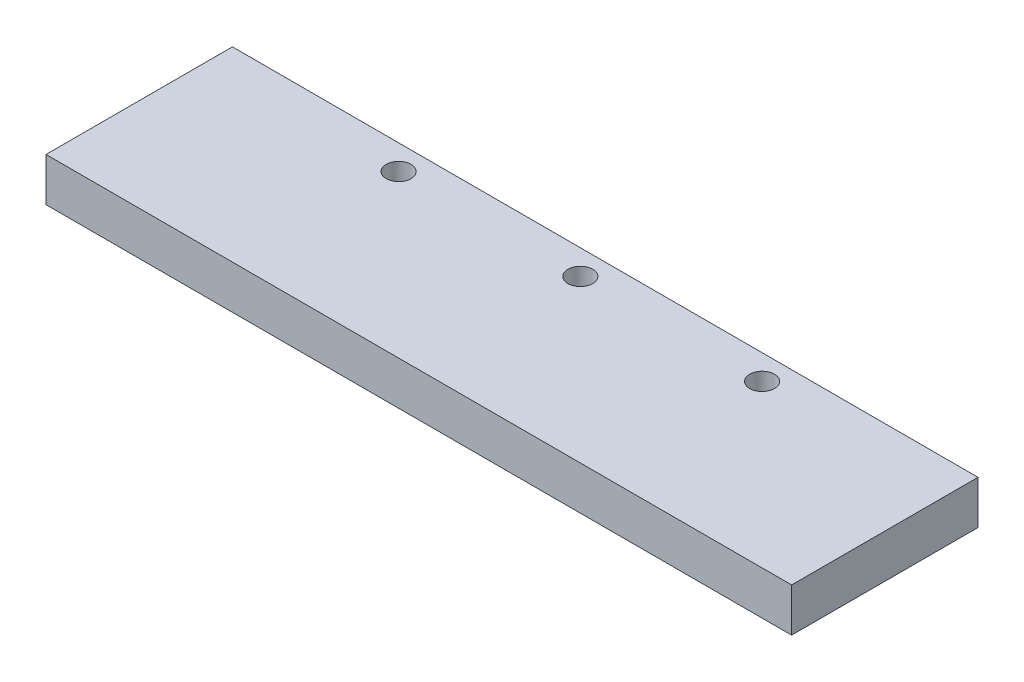
from build123d import *

# Parameters (mm, degrees)
SKETCH1_W           = 120
SKETCH1_H           = 30
BOSS_EXTRUDE1_DEPTH = 7
SKETCH2_R           = 2
CUT_EXTRUDE1_DEPTH  = 10


with BuildPart() as part:
    # Sketch1 → Boss-Extrude1 (new body)
    with BuildSketch(Plane(origin=(0, 0, 0), x_dir=(1, 0, 0), z_dir=(0, 1, 0))):
        with Locations((-42.510460251, 50.167364017)):
            Rectangle(SKETCH1_W, SKETCH1_H)
    extrude(amount=BOSS_EXTRUDE1_DEPTH)

    # Sketch2 → Cut-Extrude1 (cut)
    with BuildSketch(Plane.XZ):
        with Locations((-71.760460251, -61.167364017)):
            Circle(SKETCH2_R)
        with Locations((-42.510460251, -61.167364017)):
            Circle(SKETCH2_R)
        with Locations((-13.260460251, -61.167364017)):
            Circle(SKETCH2_R)
    extrude(amount=-CUT_EXTRUDE1_DEPTH, mode=Mode.SUBTRACT)


solid = part.part
